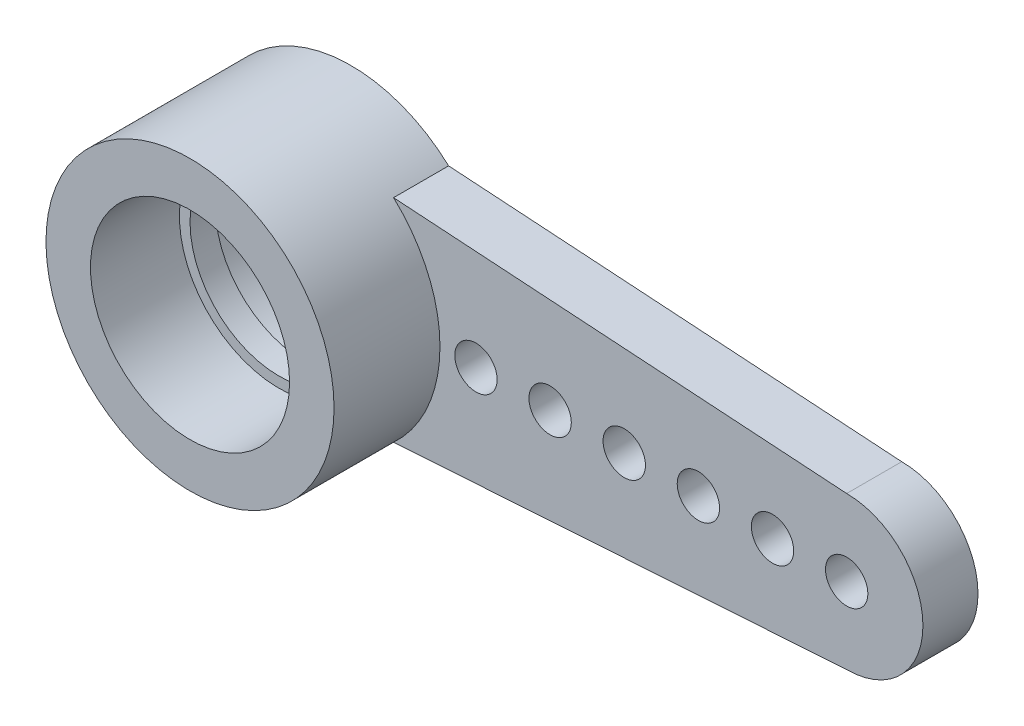
from build123d import *

# Parameters (mm, degrees)
BOSS_EXTRUDE1_DEPTH = 1.3
SKETCH2_R           = 2.35
CUT_EXTRUDE1_DEPTH  = 1.3
SKETCH3_R           = 3.4
SKETCH3_R_2         = 2.35
BOSS_EXTRUDE2_DEPTH = 2.5
BOSS_EXTRUDE3_START = -1.1
SKETCH4_R           = 2.35
SKETCH4_R_2         = 2.1
BOSS_EXTRUDE3_DEPTH = 0.6
CUT_EXTRUDE3_REACH  = 5.8
SKETCH5_R           = 0.5


with BuildPart() as part:
    # Sketch1 → Boss-Extrude1 (new body)
    with BuildSketch(Plane.XY):
        with BuildLine():
            Line((13, 1.8), (2.304343724, 2.5))
            ThreePointArc((2.304343724, 2.5), (-3.4, 0), (2.304343724, -2.5))
            Line((2.304343724, -2.5), (13, -1.8))
            ThreePointArc((13, -1.8), (14.8, 0), (13, 1.8))
        make_face()
    extrude(amount=BOSS_EXTRUDE1_DEPTH)

    # Sketch2 → Cut-Extrude1 (cut)
    with BuildSketch(Plane.XY.offset(1.3)):
        Circle(SKETCH2_R)
    extrude(amount=-CUT_EXTRUDE1_DEPTH, mode=Mode.SUBTRACT)

    # Sketch3 → Boss-Extrude2 (add)
    with BuildSketch(Plane.XY.offset(1.3)):
        Circle(SKETCH3_R)
        Circle(SKETCH3_R_2, mode=Mode.SUBTRACT)
    extrude(amount=BOSS_EXTRUDE2_DEPTH)

    # Sketch4 → Boss-Extrude3 (add)
    with BuildSketch(Plane(origin=(0, 0, 0), x_dir=(-1, 0, 0), z_dir=(0, 0, -1)).offset(BOSS_EXTRUDE3_START)):
        Circle(SKETCH4_R)
        Circle(SKETCH4_R_2, mode=Mode.SUBTRACT)
    extrude(amount=-BOSS_EXTRUDE3_DEPTH)

    # Sketch5 → Cut-Extrude3 (cut, up to next)
    with BuildSketch(Plane(origin=(0, 0, 0), x_dir=(-1, 0, 0), z_dir=(0, 0, -1)), mode=Mode.PRIVATE) as cut_extrude3_sk1:
        with Locations((-13, 0)):
            Circle(SKETCH5_R)
    cut_extrude3_tool1 = extrude(cut_extrude3_sk1.sketch, amount=-CUT_EXTRUDE3_REACH, mode=Mode.PRIVATE) & part.part
    add(cut_extrude3_tool1.solids().sort_by_distance((13, 0, 0))[0], mode=Mode.SUBTRACT)
    # Sketch5 → Cut-Extrude3 (cut, up to next)
    with BuildSketch(Plane(origin=(0, 0, 0), x_dir=(-1, 0, 0), z_dir=(0, 0, -1)), mode=Mode.PRIVATE) as cut_extrude3_sk2:
        with Locations((-11.25, 0)):
            Circle(SKETCH5_R)
    cut_extrude3_tool2 = extrude(cut_extrude3_sk2.sketch, amount=-CUT_EXTRUDE3_REACH, mode=Mode.PRIVATE) & part.part
    add(cut_extrude3_tool2.solids().sort_by_distance((11.25, 0, 0))[0], mode=Mode.SUBTRACT)
    # Sketch5 → Cut-Extrude3 (cut, up to next)
    with BuildSketch(Plane(origin=(0, 0, 0), x_dir=(-1, 0, 0), z_dir=(0, 0, -1)), mode=Mode.PRIVATE) as cut_extrude3_sk3:
        with Locations((-9.5, 0)):
            Circle(SKETCH5_R)
    cut_extrude3_tool3 = extrude(cut_extrude3_sk3.sketch, amount=-CUT_EXTRUDE3_REACH, mode=Mode.PRIVATE) & part.part
    add(cut_extrude3_tool3.solids().sort_by_distance((9.5, 0, 0))[0], mode=Mode.SUBTRACT)
    # Sketch5 → Cut-Extrude3 (cut, up to next)
    with BuildSketch(Plane(origin=(0, 0, 0), x_dir=(-1, 0, 0), z_dir=(0, 0, -1)), mode=Mode.PRIVATE) as cut_extrude3_sk4:
        with Locations((-7.75, 0)):
            Circle(SKETCH5_R)
    cut_extrude3_tool4 = extrude(cut_extrude3_sk4.sketch, amount=-CUT_EXTRUDE3_REACH, mode=Mode.PRIVATE) & part.part
    add(cut_extrude3_tool4.solids().sort_by_distance((7.75, 0, 0))[0], mode=Mode.SUBTRACT)
    # Sketch5 → Cut-Extrude3 (cut, up to next)
    with BuildSketch(Plane(origin=(0, 0, 0), x_dir=(-1, 0, 0), z_dir=(0, 0, -1)), mode=Mode.PRIVATE) as cut_extrude3_sk5:
        with Locations((-6, 0)):
            Circle(SKETCH5_R)
    cut_extrude3_tool5 = extrude(cut_extrude3_sk5.sketch, amount=-CUT_EXTRUDE3_REACH, mode=Mode.PRIVATE) & part.part
    add(cut_extrude3_tool5.solids().sort_by_distance((6, 0, 0))[0], mode=Mode.SUBTRACT)
    # Sketch5 → Cut-Extrude3 (cut, up to next)
    with BuildSketch(Plane(origin=(0, 0, 0), x_dir=(-1, 0, 0), z_dir=(0, 0, -1)), mode=Mode.PRIVATE) as cut_extrude3_sk6:
        with Locations((-4.25, 0)):
            Circle(SKETCH5_R)
    cut_extrude3_tool6 = extrude(cut_extrude3_sk6.sketch, amount=-CUT_EXTRUDE3_REACH, mode=Mode.PRIVATE) & part.part
    add(cut_extrude3_tool6.solids().sort_by_distance((4.25, 0, 0))[0], mode=Mode.SUBTRACT)


solid = part.part
